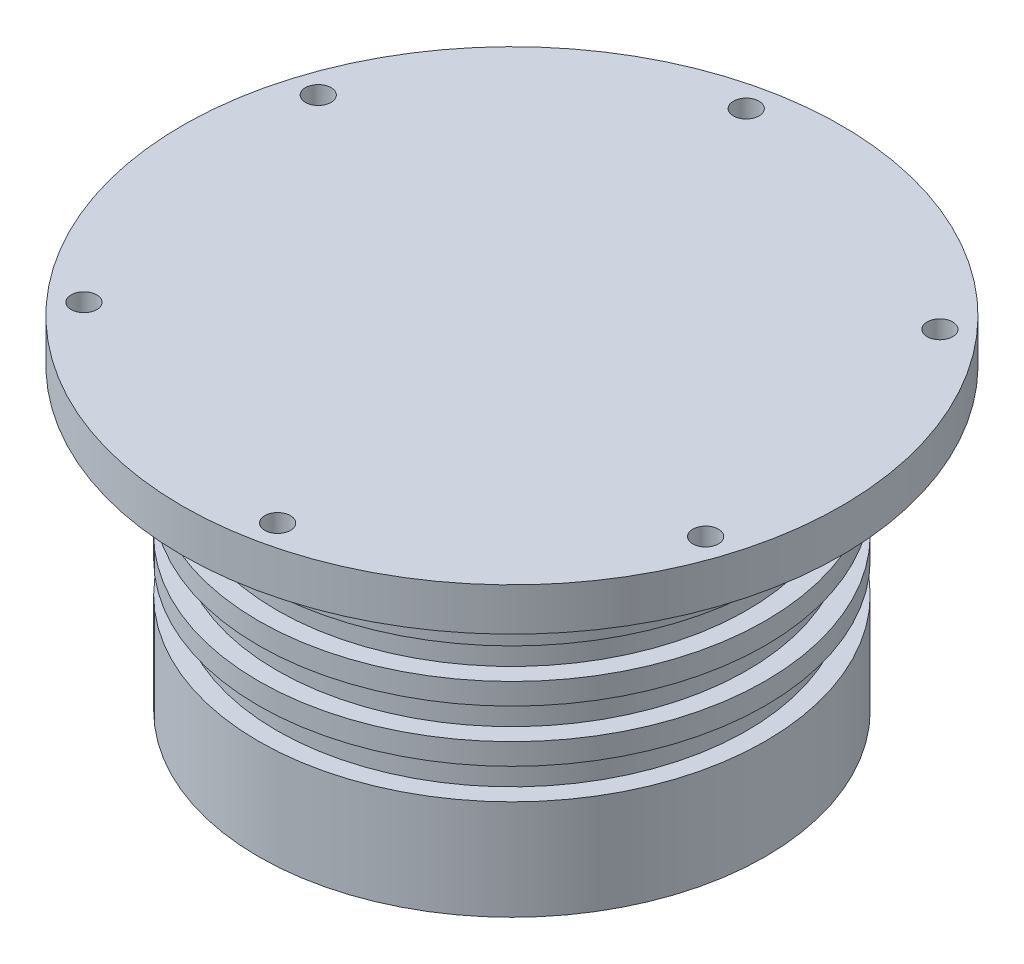
from build123d import *

# Parameters (mm, degrees)
ESQUISSE2_R             = 3
ENL_V_MAT_EXTRU_1_DEPTH = 164


with BuildPart() as part:
    # Esquisse1 → Révolution2 (revolve)
    with BuildSketch(Plane.XY, mode=Mode.PRIVATE) as r_volution2_sk:
        Polygon((0, 93.9493256), (77.14, 93.9493256), (77.14, 83.9493256), (59.3, 83.9493256), (59.3, 73.9493256), (59.3, 68.9493256), (55, 68.9493256), (55, 61.7493256), (59.3, 61.7493256), (59.3, 56.7493256), (55, 56.7493256), (55, 49.5493256), (59.3, 49.5493256), (59.3, 44.5493256), (55, 44.5493256), (55, 37.3493256), (59.3, 37.3493256), (59.3, 13.9493256), (55, 13.9493256), (0, 13.9493256), align=None)
    revolve(r_volution2_sk.sketch.rotate(Axis((0, 93.9493256, 0), (0, -1, 0)), 90), axis=Axis((0, 93.9493256, 0), (0, -1, 0)))  # turned: the seam where the file's is

    # Esquisse2 → Enlèv. mat.-Extru.1 (cut)
    with BuildSketch(Plane(origin=(0, 0, 0), x_dir=(1, 0, 0), z_dir=(0, 1, 0))):
        with Locations(Location((14.585474317, -69.42440161, 0), (0, 0, 90))):  # turned: the seam where the file's is
            Circle(ESQUISSE2_R)
        with Locations(Location((67.416032595, -22.080809521, 0), (0, 0, 90))):  # turned: the seam where the file's is
            Circle(ESQUISSE2_R)
        with Locations(Location((52.830558279, 47.34359209, 0), (0, 0, 90))):  # turned: the seam where the file's is
            Circle(ESQUISSE2_R)
        with Locations(Location((-14.585474317, 69.42440161, 0), (0, 0, 90))):  # turned: the seam where the file's is
            Circle(ESQUISSE2_R)
        with Locations(Location((-67.416032595, 22.080809521, 0), (0, 0, 90))):  # turned: the seam where the file's is
            Circle(ESQUISSE2_R)
        with Locations(Location((-52.830558279, -47.34359209, 0), (0, 0, 90))):  # turned: the seam where the file's is
            Circle(ESQUISSE2_R)
    extrude(amount=ENL_V_MAT_EXTRU_1_DEPTH, mode=Mode.SUBTRACT)


solid = part.part
